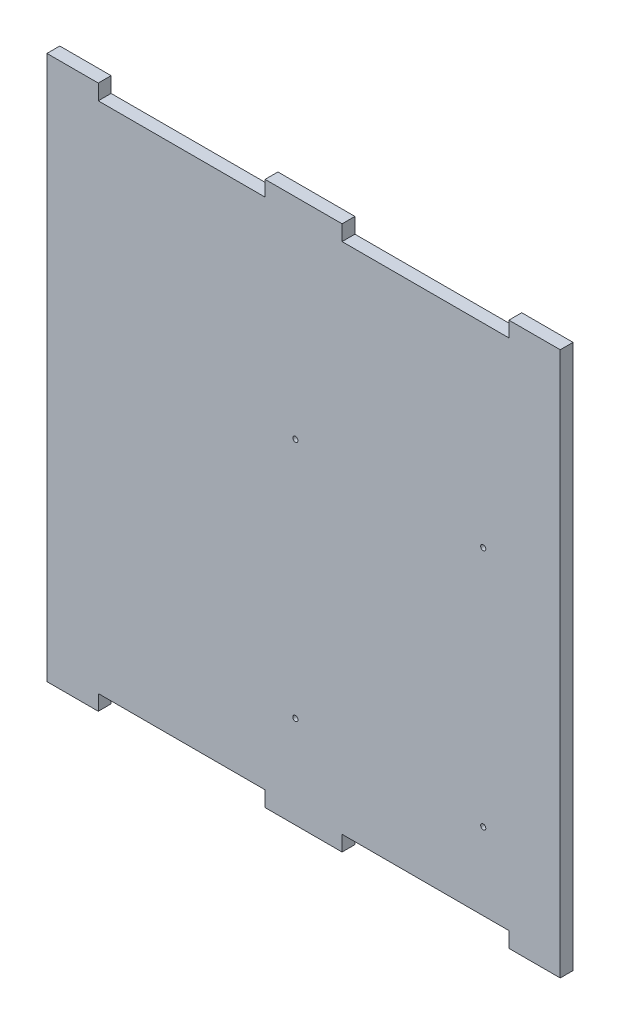
from build123d import *

# Parameters (mm, degrees)
ESQUISSE1_R        = 1
BOSS_EXTRU_1_DEPTH = 5


with BuildPart() as part:
    # Esquisse1 → Boss.-Extru.1 (new body)
    with BuildSketch(Plane.XY):
        Polygon((0, 0), (0, 212), (20, 212), (20, 206), (85, 206), (85, 212), (115, 212), (115, 206), (180, 206), (180, 212), (200, 212), (200, 0), (180, 0), (180, 6), (115, 6), (115, 0), (85, 0), (85, 6), (20, 6), (20, 0), align=None)
        with Locations((170, 36)):
            Circle(ESQUISSE1_R, mode=Mode.SUBTRACT)
        with Locations((96.8, 36)):
            Circle(ESQUISSE1_R, mode=Mode.SUBTRACT)
        with Locations((96.8, 130.2)):
            Circle(ESQUISSE1_R, mode=Mode.SUBTRACT)
        with Locations((170, 130.2)):
            Circle(ESQUISSE1_R, mode=Mode.SUBTRACT)
    extrude(amount=BOSS_EXTRU_1_DEPTH)


solid = part.part
